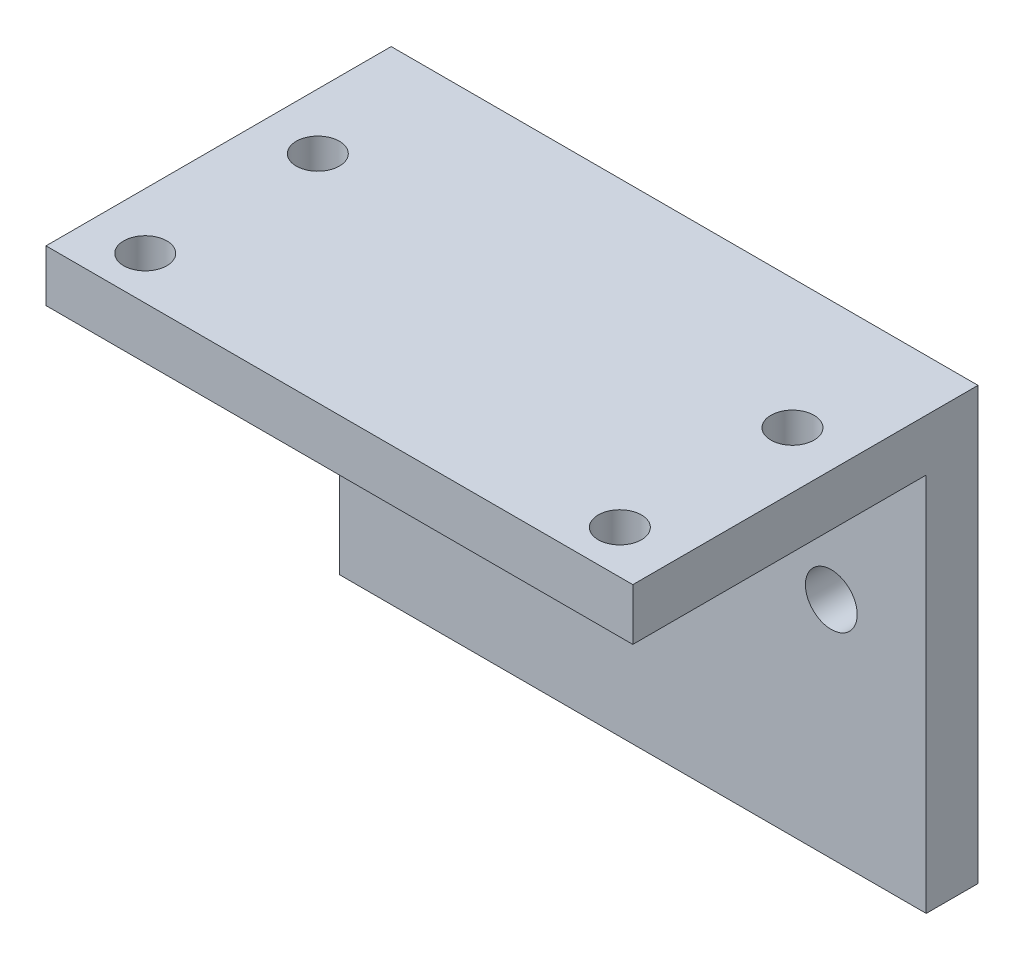
from build123d import *

# Parameters (mm, degrees)
SKETCH_1_W          = 68
SKETCH_1_H          = 40
SKETCH_1_R          = 2.5
EXTRUDE_1_DEPTH     = 6
SKETCH_3_W          = 68
SKETCH_3_H          = 6
EXTRUDE_2_DEPTH     = 50
CUT_EXTRUDE_1_REACH = 8
SKETCH_4_R          = 8
SKETCH_4_R_2        = 3


with BuildPart() as part:
    # 草图1 → 凸台-拉伸1 (new body)
    with BuildSketch(Plane(origin=(0, 0, 0), x_dir=(1, 0, 0), z_dir=(0, 1, 0))):
        with Locations((0, 20)):
            Rectangle(SKETCH_1_W, SKETCH_1_H)
        with Locations((-27.5, 25)):
            Circle(SKETCH_1_R, mode=Mode.SUBTRACT)
        with Locations((27.5, 25)):
            Circle(SKETCH_1_R, mode=Mode.SUBTRACT)
        with Locations((-27.5, 5)):
            Circle(SKETCH_1_R, mode=Mode.SUBTRACT)
        with Locations((27.5, 5)):
            Circle(SKETCH_1_R, mode=Mode.SUBTRACT)
    extrude(amount=EXTRUDE_1_DEPTH)

    # 草图3 → 凸台-拉伸2 (add)
    with BuildSketch(Plane(origin=(0, 6, 0), x_dir=(1, 0, 0), z_dir=(0, 1, 0))):
        with Locations((0, 37)):
            Rectangle(SKETCH_3_W, SKETCH_3_H)
    extrude(amount=-EXTRUDE_2_DEPTH)

    # 草图4 → 切除-拉伸1 (cut, up to next)
    with BuildSketch(Plane.XY.offset(-34), mode=Mode.PRIVATE) as cut_extrude_1_sk1:
        with Locations((-1, -18)):
            Circle(SKETCH_4_R)
    cut_extrude_1_tool1 = extrude(cut_extrude_1_sk1.sketch, amount=-CUT_EXTRUDE_1_REACH, mode=Mode.PRIVATE) & part.part
    add(cut_extrude_1_tool1.solids().sort_by_distance((-1, -18, -34))[0], mode=Mode.SUBTRACT)
    # 草图4 → 切除-拉伸1 (cut, up to next)
    with BuildSketch(Plane.XY.offset(-34), mode=Mode.PRIVATE) as cut_extrude_1_sk2:
        with Locations((23, -18)):
            Circle(SKETCH_4_R_2)
    cut_extrude_1_tool2 = extrude(cut_extrude_1_sk2.sketch, amount=-CUT_EXTRUDE_1_REACH, mode=Mode.PRIVATE) & part.part
    add(cut_extrude_1_tool2.solids().sort_by_distance((23, -18, -34))[0], mode=Mode.SUBTRACT)
    # 草图4 → 切除-拉伸1 (cut, up to next)
    with BuildSketch(Plane.XY.offset(-34), mode=Mode.PRIVATE) as cut_extrude_1_sk3:
        with Locations((-25, -18)):
            Circle(SKETCH_4_R_2)
    cut_extrude_1_tool3 = extrude(cut_extrude_1_sk3.sketch, amount=-CUT_EXTRUDE_1_REACH, mode=Mode.PRIVATE) & part.part
    add(cut_extrude_1_tool3.solids().sort_by_distance((-25, -18, -34))[0], mode=Mode.SUBTRACT)


solid = part.part
